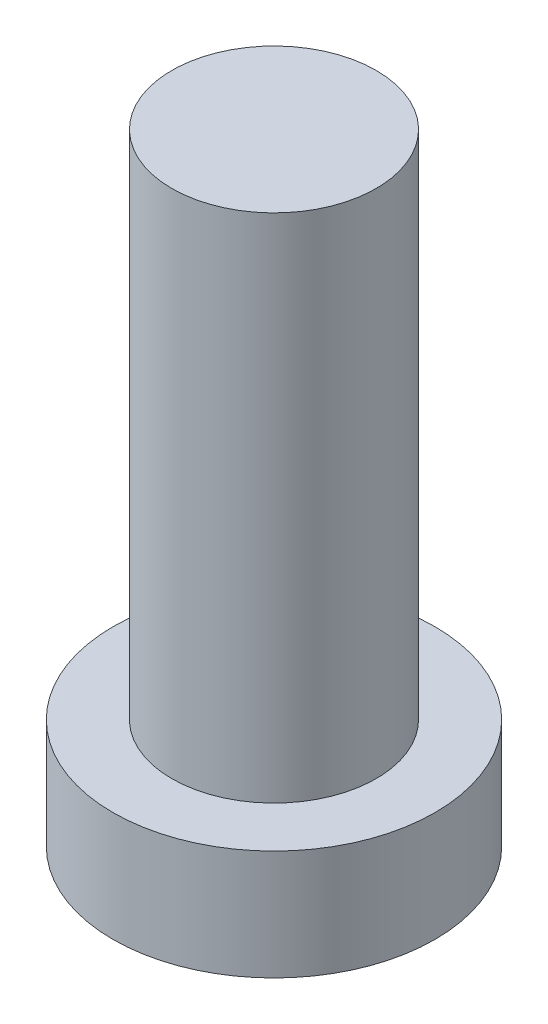
from build123d import *

# Parameters (mm, degrees)
SKETCH_1_R          = 3.15
EXTRUDE_1_DEPTH     = 2.15
SKETCH_2_R          = 2
EXTRUDE_2_DEPTH     = 10
CUT_EXTRUDE_1_DEPTH = 1.5


with BuildPart() as part:
    # 草图1 → 凸台-拉伸1 (new body)
    with BuildSketch(Plane(origin=(0, 0, 0), x_dir=(1, 0, 0), z_dir=(0, 1, 0))):
        Circle(SKETCH_1_R)
    extrude(amount=EXTRUDE_1_DEPTH)

    # 草图2 → 凸台-拉伸2 (add)
    with BuildSketch(Plane(origin=(0, 2.15, 0), x_dir=(1, 0, 0), z_dir=(0, 1, 0))):
        Circle(SKETCH_2_R)
    extrude(amount=EXTRUDE_2_DEPTH)

    # 草图3 → 切除-拉伸1 (cut)
    with BuildSketch(Plane.XZ):
        with BuildLine():
            Line((-0.5, 1), (-0.5, 2))
            Line((-0.5, 2), (0.5, 2))
            Line((0.5, 2), (0.5, 1))
            ThreePointArc((0.5, 1), (0.646446609, 0.646446609), (1, 0.5))
            Line((1, 0.5), (2, 0.5))
            Line((2, 0.5), (2, -0.5))
            Line((2, -0.5), (1, -0.5))
            ThreePointArc((1, -0.5), (0.646446609, -0.646446609), (0.5, -1))
            Line((0.5, -1), (0.5, -2))
            Line((0.5, -2), (-0.5, -2))
            Line((-0.5, -2), (-0.5, -1))
            ThreePointArc((-0.5, -1), (-0.646446609, -0.646446609), (-1, -0.5))
            Line((-1, -0.5), (-2, -0.5))
            Line((-2, -0.5), (-2, 0.5))
            Line((-2, 0.5), (-1, 0.5))
            ThreePointArc((-1, 0.5), (-0.646446609, 0.646446609), (-0.5, 1))
        make_face()
    extrude(amount=-CUT_EXTRUDE_1_DEPTH, mode=Mode.SUBTRACT)


solid = part.part
